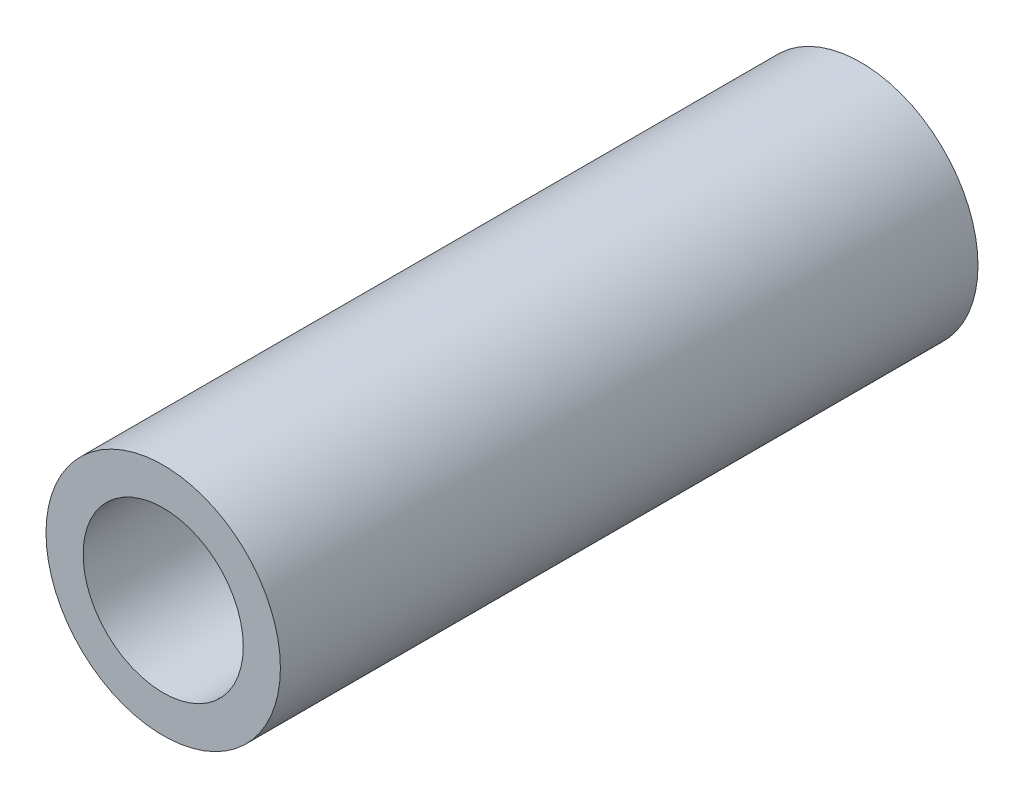
from build123d import *

# Parameters (mm, degrees)
SKETCH1_R           = 10.668
SKETCH1_R_2         = 7.2898
BOSS_EXTRUDE1_DEPTH = 63.5


with BuildPart() as part:
    # Sketch1 → Boss-Extrude1 (new body)
    with BuildSketch(Plane.XY):
        Circle(SKETCH1_R)
        Circle(SKETCH1_R_2, mode=Mode.SUBTRACT)
    extrude(amount=BOSS_EXTRUDE1_DEPTH)


solid = part.part
